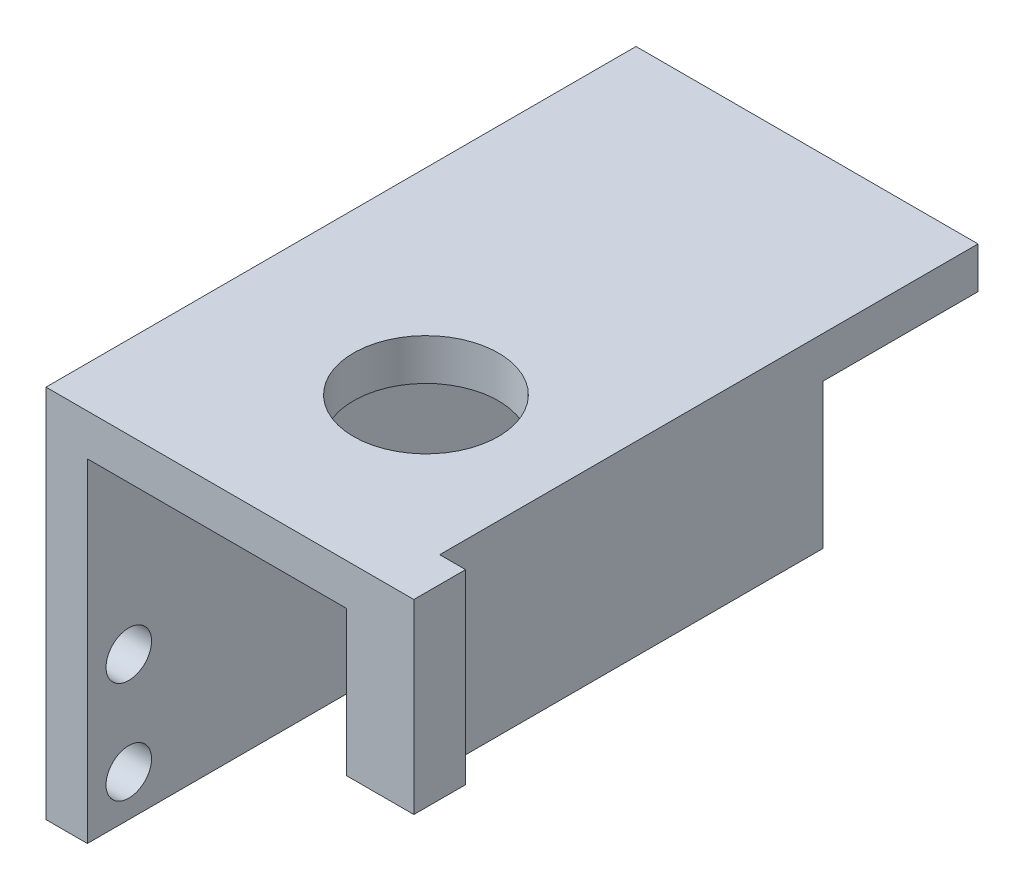
from build123d import *

# Parameters (mm, degrees)
SKETCH1_W           = 57.02
SKETCH1_H           = 36.2
SKETCH1_R           = 2.2
BOSS_EXTRUDE1_DEPTH = 4
SKETCH2_W           = 57.02
SKETCH2_H           = 4
BOSS_EXTRUDE2_DEPTH = 29.05
SKETCH3_W           = 4
SKETCH3_H           = 42.02
BOSS_EXTRUDE3_DEPTH = 14
SKETCH5_R           = 7
CUT_EXTRUDE1_DEPTH  = 4
SKETCH6_W           = 5
SKETCH6_H           = 18
BOSS_EXTRUDE4_DEPTH = 2.5


with BuildPart() as part:
    # Sketch1 → Boss-Extrude1 (new body)
    with BuildSketch(Plane(origin=(0, 0, 0), x_dir=(0, 0, -1), z_dir=(1, 0, 0))):
        Rectangle(SKETCH1_W, SKETCH1_H)
        with Locations((-24.51, -4.25)):
            Circle(SKETCH1_R, mode=Mode.SUBTRACT)
        with Locations((-24.51, -14.1)):
            Circle(SKETCH1_R, mode=Mode.SUBTRACT)
        with Locations((24.51, -4.25)):
            Circle(SKETCH1_R, mode=Mode.SUBTRACT)
        with Locations((24.51, -14.1)):
            Circle(SKETCH1_R, mode=Mode.SUBTRACT)
    extrude(amount=BOSS_EXTRUDE1_DEPTH)

    # Sketch2 → Boss-Extrude2 (add)
    with BuildSketch(Plane(origin=(4, 0, 0), x_dir=(0, 0, -1), z_dir=(1, 0, 0))):
        with Locations((0, 16.1)):
            Rectangle(SKETCH2_W, SKETCH2_H)
    extrude(amount=BOSS_EXTRUDE2_DEPTH)

    # Sketch3 → Boss-Extrude3 (add)
    with BuildSketch(Plane.XZ.offset(-14.1)):
        with Locations((31.05, 7.5)):
            Rectangle(SKETCH3_W, SKETCH3_H)
    extrude(amount=BOSS_EXTRUDE3_DEPTH)

    # Sketch5 → Cut-Extrude1 (cut)
    with BuildSketch(Plane(origin=(0, 18.1, 0), x_dir=(1, 0, 0), z_dir=(0, 1, 0))):
        with Locations((19, -10.79)):
            Circle(SKETCH5_R)
    extrude(amount=-CUT_EXTRUDE1_DEPTH, mode=Mode.SUBTRACT)

    # Sketch6 → Boss-Extrude4 (add)
    with BuildSketch(Plane(origin=(33.05, 0, 0), x_dir=(0, 0, -1), z_dir=(1, 0, 0))):
        with Locations((-26.01, 9.1)):
            Rectangle(SKETCH6_W, SKETCH6_H)
    extrude(amount=BOSS_EXTRUDE4_DEPTH)


solid = part.part
